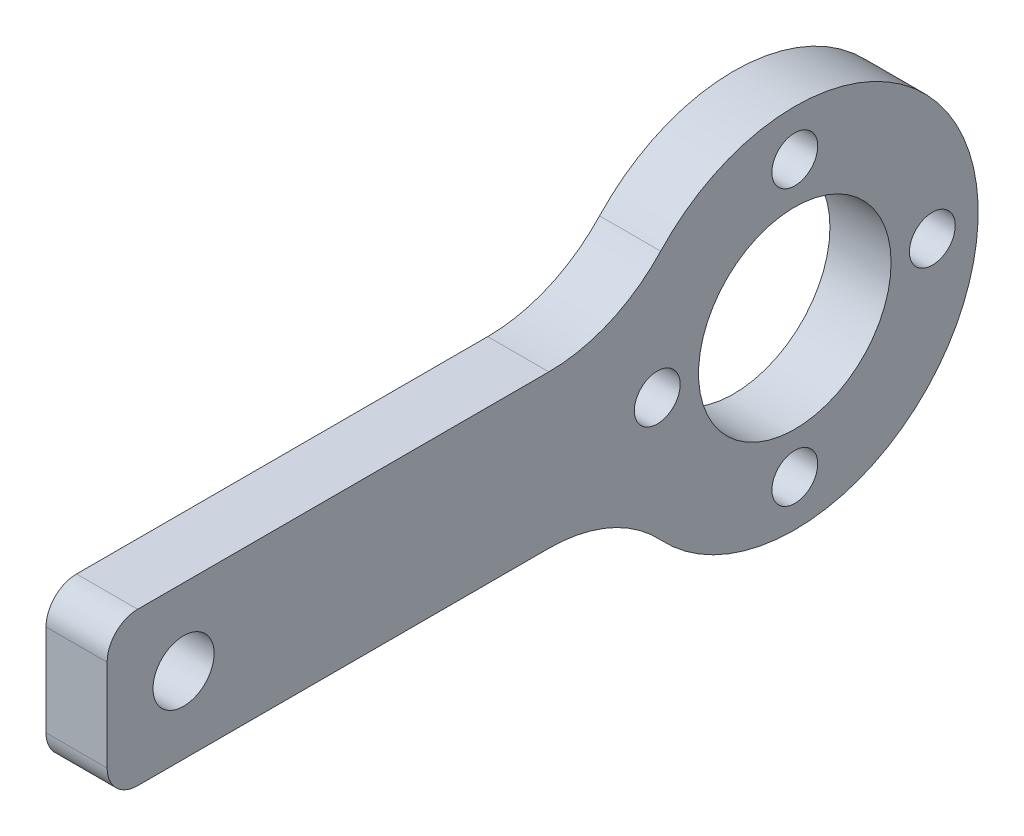
from build123d import *

# Parameters (mm, degrees)
SKETCH_1_R          = 12
SKETCH_1_R_2        = 1.5
SKETCH_1_R_3        = 6.3
EXTRUDE_1_DEPTH     = 4
SKETCH_6_W          = 40
SKETCH_6_H          = 10
SKETCH_6_R          = 2
SKETCH_6_R_2        = 1.5
EXTRUDE_5_DEPTH     = 4
FILLET_1_R          = 10
FILLET_2_R          = 2
SKETCH_7_R          = 6.3
CUT_EXTRUDE_1_DEPTH = 5


with BuildPart() as part:
    # 草图1 → 凸台-拉伸1 (new body)
    with BuildSketch(Plane(origin=(0, 0, 0), x_dir=(0, 0, -1), z_dir=(1, 0, 0))):
        Circle(SKETCH_1_R)
        with Locations((0, 9)):
            Circle(SKETCH_1_R_2, mode=Mode.SUBTRACT)
        Circle(SKETCH_1_R_3, mode=Mode.SUBTRACT)
        with Locations((9, 0)):
            Circle(SKETCH_1_R_2, mode=Mode.SUBTRACT)
        with Locations((0, -9)):
            Circle(SKETCH_1_R_2, mode=Mode.SUBTRACT)
        with Locations((-9, 0)):
            Circle(SKETCH_1_R_2, mode=Mode.SUBTRACT)
    extrude(amount=EXTRUDE_1_DEPTH)

    # 草图6 → 凸台-拉伸5 (add)
    with BuildSketch(Plane(origin=(4, 0, 0), x_dir=(0, 0, -1), z_dir=(1, 0, 0))):
        with Locations((-25, 0)):
            Rectangle(SKETCH_6_W, SKETCH_6_H)
        with Locations((-40, 0)):
            Circle(SKETCH_6_R, mode=Mode.SUBTRACT)
        with Locations((-9, 0)):
            Circle(SKETCH_6_R_2, mode=Mode.SUBTRACT)
    extrude(amount=-EXTRUDE_5_DEPTH)

    # 圆角1
    fillet_1_edges = [part.edges().sort_by_distance(p)[0] for p in [
        (2, 5, 10.908712115),
        (2, -5, 10.908712115),
    ]]
    fillet(fillet_1_edges, radius=FILLET_1_R)

    # 圆角2
    fillet_2_edges = [part.edges().sort_by_distance(p)[0] for p in [
        (2, 5, 45),
        (2, -5, 45),
    ]]
    fillet(fillet_2_edges, radius=FILLET_2_R)

    # 草图7 → 切除-拉伸1 (cut, symmetric)
    with BuildSketch(Plane(origin=(4, 0, 0), x_dir=(0, 0, -1), z_dir=(1, 0, 0))):
        Circle(SKETCH_7_R)
    extrude(amount=CUT_EXTRUDE_1_DEPTH, both=True, mode=Mode.SUBTRACT)


solid = part.part
